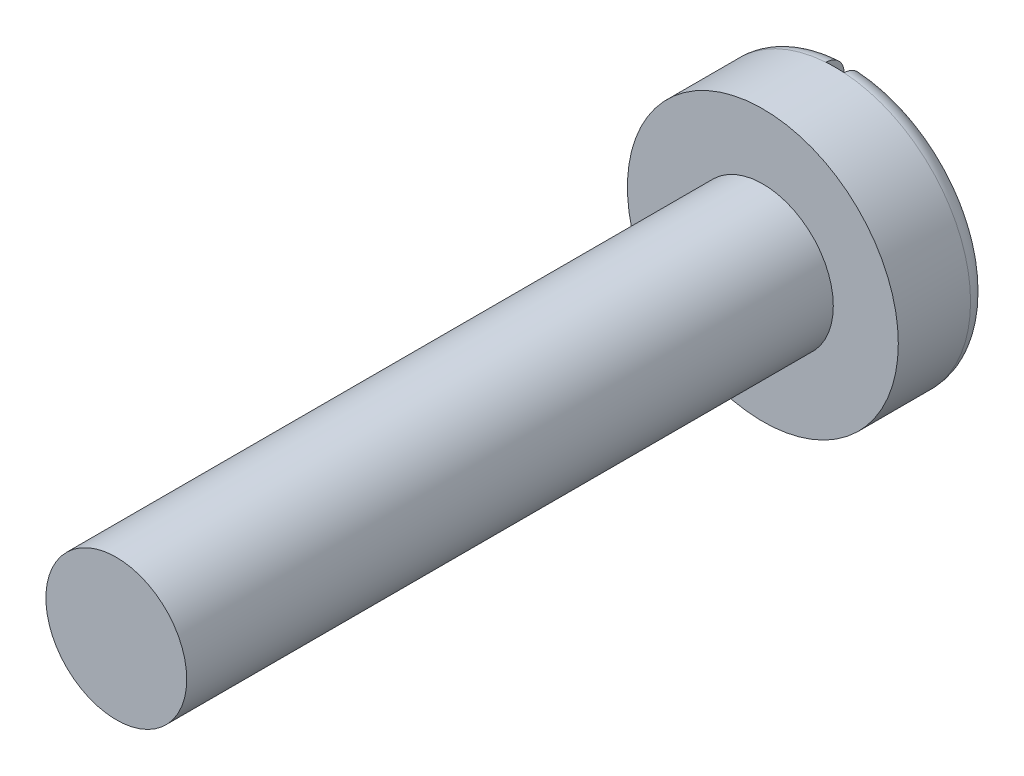
from build123d import *

# Parameters (mm, degrees)
CUT_EXTRUDE1_DEPTH = 0.254
FILLET1_R          = 0.254


with BuildPart() as part:
    # Sketch3 → Revolve1 (revolve)
    with BuildSketch(Plane(origin=(0, 0, 0), x_dir=(0, 0, -1), z_dir=(1, 0, 0)), mode=Mode.PRIVATE) as revolve1_sk:
        Polygon((0, 1.905), (1.27, 1.905), (1.27, 0), (0, 0), (-9.0932, 0), (-9.0932, 0.9906), (0, 0.9906), align=None)
    revolve(revolve1_sk.sketch.rotate(Axis((0, 0, 55), (0, 0, -1)), 90), axis=Axis((0, 0, 55), (0, 0, -1)))

    # Sketch4 → Cut-Extrude1 (cut)
    with BuildSketch(Plane(origin=(0, 0, -1.27), x_dir=(-1, 0, 0), z_dir=(0, 0, -1))):
        with BuildLine():
            Line((0, -1.905), (0, 1.905))
            ThreePointArc((0, 1.905), (-0.063535, 1.90394), (-0.127, 1.900762))
            Line((-0.127, 1.900762), (-0.127, -1.900762))
            ThreePointArc((-0.127, -1.900762), (-0.063535, -1.90394), (0, -1.905))
        make_face()
        with BuildLine():
            ThreePointArc((0.127, 1.900762), (0.063535, 1.90394), (0, 1.905))
            Line((0, 1.905), (0, -1.905))
            ThreePointArc((0, -1.905), (0.063535, -1.90394), (0.127, -1.900762))
            Line((0.127, -1.900762), (0.127, 1.900762))
        make_face()
    extrude(amount=-CUT_EXTRUDE1_DEPTH, mode=Mode.SUBTRACT)

    # Fillet1
    fillet1_edges = [part.edges().sort_by_distance(p)[0] for p in [
        (-1.905, 0, -1.27),
        (1.391215, 1.301363, -1.27),
    ]]
    fillet(fillet1_edges, radius=FILLET1_R)


solid = part.part
